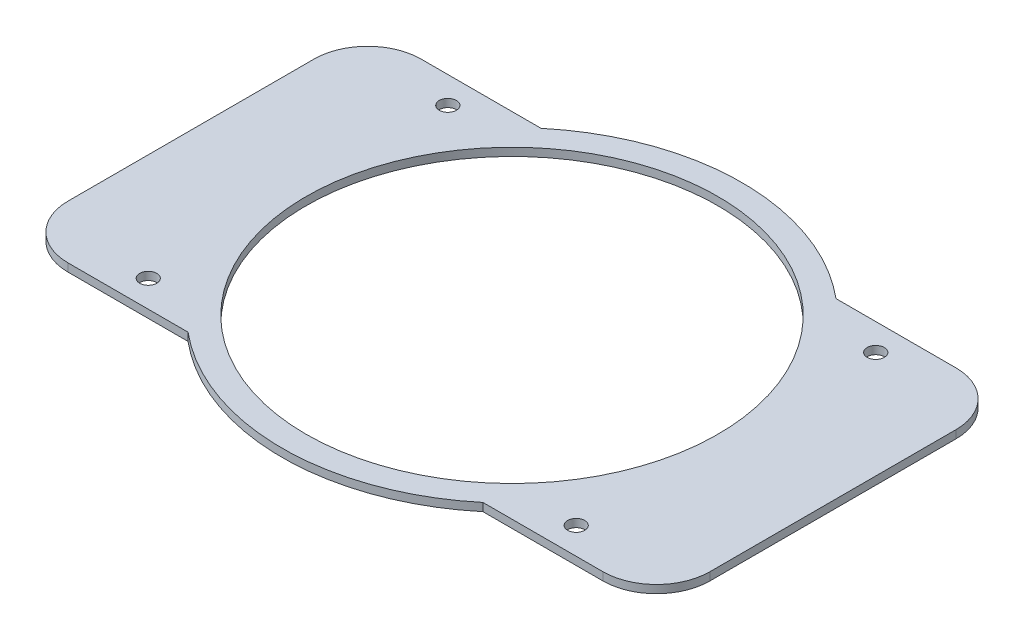
from build123d import *

# Parameters (mm, degrees)
SKETCH2_R           = 38.5
BOSS_EXTRUDE4_DEPTH = 1.5
BOSS_EXTRUDE5_DEPTH = 1.5
SKETCH4_R           = 1.6
CUT_EXTRUDE1_DEPTH  = 1.5
FILLET1_R           = 10


with BuildPart() as part:
    # Sketch2 → Boss-Extrude4 (new body)
    with BuildSketch(Plane(origin=(0, 0, 0), x_dir=(1, 0, 0), z_dir=(0, 1, 0))):
        with BuildLine():
            Line((-60, 32), (-28.722813233, 32))
            ThreePointArc((-28.722813233, 32), (0, 43), (28.722813233, 32))
            Line((28.722813233, 32), (60, 32))
            Line((60, 32), (60, -32))
            Line((60, -32), (28.722813233, -32))
            ThreePointArc((28.722813233, -32), (0, -43), (-28.722813233, -32))
            Line((-28.722813233, -32), (-60, -32))
            Line((-60, -32), (-60, 32))
        make_face()
        Circle(SKETCH2_R, mode=Mode.SUBTRACT)
    extrude(amount=BOSS_EXTRUDE4_DEPTH)

    # Sketch3 → Boss-Extrude5 (add)
    with BuildSketch(Plane(origin=(0, 1.5, 0), x_dir=(1, 0, 0), z_dir=(0, 1, 0))):
        Polygon((60, 32), (60, 33), (22.967632109, 33), (40.759186936, 20.496414307), (60, 20.496414307), align=None)
        Polygon((60, -20.496414307), (60, -32), (60, -33), (22.967632109, -33), (40.759186936, -20.496414307), align=None)
        Polygon((-60, -32), (-60, -33), (-22.967632109, -33), (-40.759186936, -20.496414307), (-60, -20.496414307), align=None)
        Polygon((-60, 20.496414307), (-60, 32), (-60, 33), (-22.967632109, 33), (-40.759186936, 20.496414307), align=None)
    extrude(amount=-BOSS_EXTRUDE5_DEPTH)

    # Sketch4 → Cut-Extrude1 (cut)
    with BuildSketch(Plane(origin=(0, 1.5, 0), x_dir=(1, 0, 0), z_dir=(0, 1, 0))):
        with Locations((40, 28)):
            Circle(SKETCH4_R)
        with Locations((40, -28)):
            Circle(SKETCH4_R)
        with Locations((-40, -28)):
            Circle(SKETCH4_R)
        with Locations((-40, 28)):
            Circle(SKETCH4_R)
    extrude(amount=-CUT_EXTRUDE1_DEPTH, mode=Mode.SUBTRACT)

    # Fillet1
    fillet1_edges = [part.edges().sort_by_distance(p)[0] for p in [
        (60, 0.75, -33),
        (60, 0.75, 33),
        (-60, 0.75, 33),
        (-60, 0.75, -33),
    ]]
    fillet(fillet1_edges, radius=FILLET1_R)


solid = part.part
